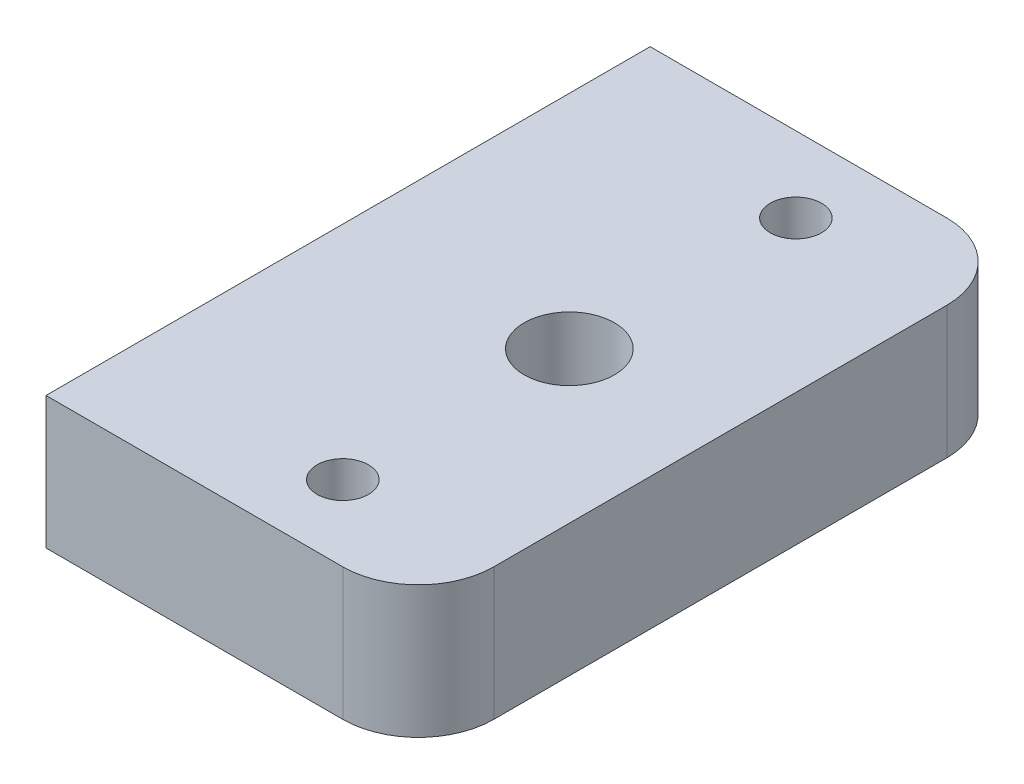
from build123d import *

# Parameters (mm, degrees)
SKETCH1_W      = 15.65275
SKETCH1_H      = 25.4
SKETCH1_R      = 1.89865
SKETCH1_R_2    = 1.0795
EXTRUDE1_DEPTH = 5.55625
FILLET1_R      = 3.175


with BuildPart() as part:
    # Sketch1 → Extrude1 (new body)
    with BuildSketch(Plane(origin=(0, 0, 0), x_dir=(1, 0, 0), z_dir=(0, 1, 0))):
        with Locations((-1.476375, 0)):
            Rectangle(SKETCH1_W, SKETCH1_H)
        with Locations(Location((0, 0, 0), (0, 0, 270))):
            Circle(SKETCH1_R, mode=Mode.SUBTRACT)
        with Locations(Location((0, 9.525, 0), (0, 0, 270))):
            Circle(SKETCH1_R_2, mode=Mode.SUBTRACT)
        with Locations(Location((0, -9.525, 0), (0, 0, 270))):
            Circle(SKETCH1_R_2, mode=Mode.SUBTRACT)
    extrude(amount=EXTRUDE1_DEPTH)

    # Fillet1
    fillet1_edges = [part.edges().sort_by_distance(p)[0] for p in [
        (6.35, 2.778125, -12.7),
        (6.35, 2.778125, 12.7),
    ]]
    fillet(fillet1_edges, radius=FILLET1_R)


solid = part.part
